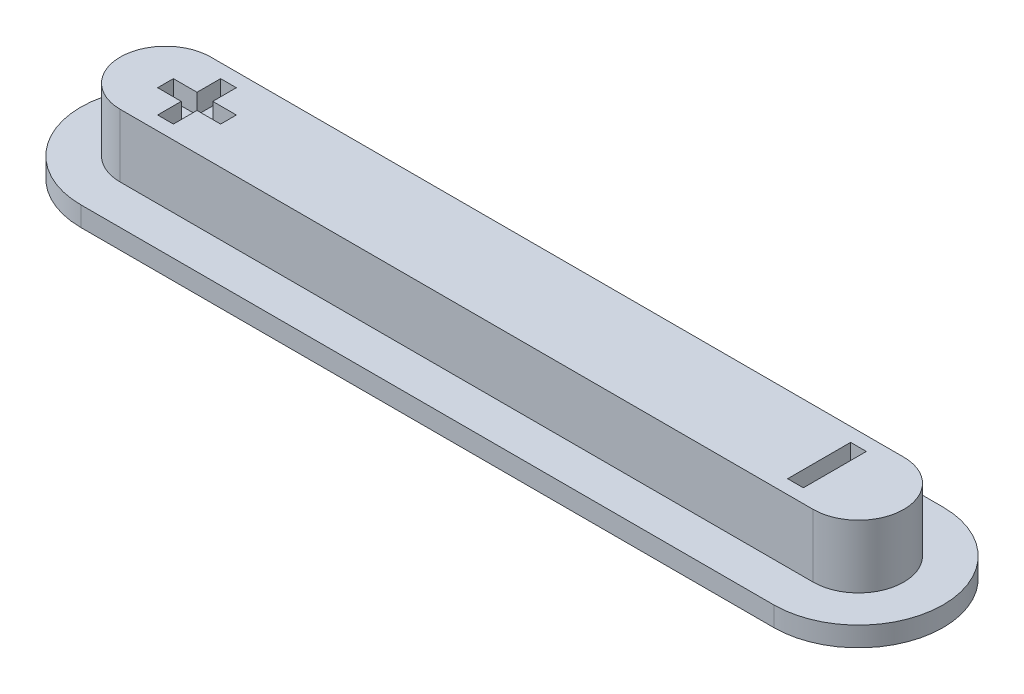
from build123d import *

# Parameters (mm, degrees)
EXTRUDE_1_DEPTH     = 1.6
EXTRUDE_2_DEPTH     = 0.5
SKETCH_3_W          = 0.4
SKETCH_3_H          = 1.6
SKETCH_3_W_2        = 0.6
SKETCH_3_H_2        = 0.4
SKETCH_3_H_3        = 0.6
CUT_EXTRUDE_1_DEPTH = 0.5


with BuildPart() as part:
    # 草图1 → 凸台-拉伸1 (new body)
    with BuildSketch(Plane(origin=(0, 0, 0), x_dir=(1, 0, 0), z_dir=(0, 1, 0))):
        with BuildLine():
            Line((-8.8, 1.15), (8.8, 1.15))
            ThreePointArc((8.8, 1.15), (9.95, 0), (8.8, -1.15))
            Line((8.8, -1.15), (-8.8, -1.15))
            ThreePointArc((-8.8, -1.15), (-9.95, 0), (-8.8, 1.15))
        make_face()
    extrude(amount=EXTRUDE_1_DEPTH)

    # 草图2 → 凸台-拉伸2 (add)
    with BuildSketch(Plane.XZ):
        with BuildLine():
            Line((-8.8, -2.15), (8.8, -2.15))
            ThreePointArc((8.8, -2.15), (10.95, 0), (8.8, 2.15))
            Line((8.8, 2.15), (-8.8, 2.15))
            ThreePointArc((-8.8, 2.15), (-10.95, 0), (-8.8, -2.15))
        make_face()
    extrude(amount=EXTRUDE_2_DEPTH)

    # 草图3 → 切除-拉伸1 (cut)
    with BuildSketch(Plane(origin=(0, 1.6, 0), x_dir=(1, 0, 0), z_dir=(0, 1, 0))):
        with Locations((8, 0)):
            Rectangle(SKETCH_3_W, SKETCH_3_H)
        with Locations((-8.5, 0)):
            Rectangle(SKETCH_3_W_2, SKETCH_3_H_2)
        with Locations((-8, 0)):
            Rectangle(SKETCH_3_W, SKETCH_3_H_2)
        with Locations((-8, 0.5)):
            Rectangle(SKETCH_3_W, SKETCH_3_H_3)
        with Locations((-7.5, 0)):
            Rectangle(SKETCH_3_W_2, SKETCH_3_H_2)
        with Locations((-8, -0.5)):
            Rectangle(SKETCH_3_W, SKETCH_3_H_3)
    extrude(amount=-CUT_EXTRUDE_1_DEPTH, mode=Mode.SUBTRACT)


solid = part.part
